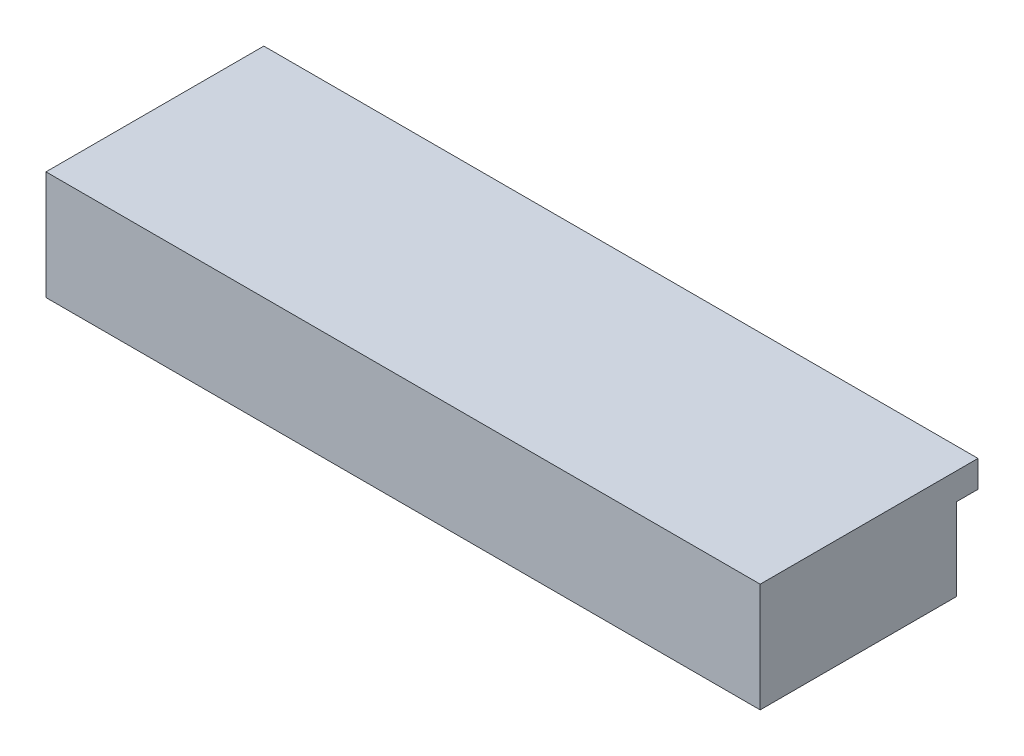
from build123d import *

# Parameters (mm, degrees)
ESQUISSE3_W      = 400
ESQUISSE3_H      = 40
EXTRUSION1_DEPTH = 110
ESQUISSE8_W      = 400
ESQUISSE8_H      = 122
EXTRUSION3_DEPTH = 15
ESQUISSE11_W     = 400
ESQUISSE11_H     = 110
EXTRUSION5_DEPTH = 6
ESQUISSE10_R     = 3
EXTRUSION4_DEPTH = 1
ESQUISSE12_R     = 3
EXTRUSION6_DEPTH = 20


with BuildPart() as part:
    # Esquisse3 → Extrusion1 (new body)
    with BuildSketch(Plane.XY):
        with Locations((38, 5)):
            Rectangle(ESQUISSE3_W, ESQUISSE3_H)
    extrude(amount=EXTRUSION1_DEPTH)

    # Esquisse8 → Extrusion3 (add)
    with BuildSketch(Plane(origin=(0, 25, 0), x_dir=(1, 0, 0), z_dir=(0, 1, 0))):
        with Locations((38, -49)):
            Rectangle(ESQUISSE8_W, ESQUISSE8_H)
    extrude(amount=EXTRUSION3_DEPTH)

    # Esquisse11 → Extrusion5 (add)
    with BuildSketch(Plane.XZ.offset(15)):
        with Locations((38, 55)):
            Rectangle(ESQUISSE11_W, ESQUISSE11_H)
    extrude(amount=EXTRUSION5_DEPTH)

    # Esquisse10 → Extrusion4 (cut)
    with BuildSketch(Plane(origin=(0, 0, 0), x_dir=(-1, 0, 0), z_dir=(0, 0, -1))):
        with BuildLine():
            Line((59.5, -8), (59.5, -19))
            ThreePointArc((59.5, -19), (58.914213562, -20.414213562), (57.5, -21))
            Line((57.5, -21), (-68.5, -21))
            ThreePointArc((-68.5, -21), (-69.914213562, -20.414213562), (-70.5, -19))
            Line((-70.5, -19), (-70.5, -8))
            ThreePointArc((-70.5, -8), (-71.085786438, -6.585786438), (-72.5, -6))
            Line((-72.5, -6), (-83, -6))
            ThreePointArc((-83, -6), (-95.5, 6.5), (-83, 19))
            Line((-83, 19), (70.25, 19))
            ThreePointArc((70.25, 19), (82.75, 6.5), (70.25, -6))
            Line((70.25, -6), (61.5, -6))
            ThreePointArc((61.5, -6), (60.085786438, -6.585786438), (59.5, -8))
        make_face()
        with Locations((-86.5, 6.5)):
            Circle(ESQUISSE10_R, mode=Mode.SUBTRACT)
        with Locations((-20.5, 6.5)):
            Circle(ESQUISSE10_R, mode=Mode.SUBTRACT)
        with Locations((72.75, 6.5)):
            Circle(ESQUISSE10_R, mode=Mode.SUBTRACT)
        with BuildLine():
            Line((-31.5, -3), (-61.5, -3))
            ThreePointArc((-61.5, -3), (-62.207106781, -2.707106781), (-62.5, -2))
            Line((-62.5, -2), (-62.5, 12))
            ThreePointArc((-62.5, 12), (-62.207106781, 12.707106781), (-61.5, 13))
            Line((-61.5, 13), (-31.5, 13))
            ThreePointArc((-31.5, 13), (-30.792893219, 12.707106781), (-30.5, 12))
            Line((-30.5, 12), (-30.5, -2))
            ThreePointArc((-30.5, -2), (-30.792893219, -2.707106781), (-31.5, -3))
        make_face(mode=Mode.SUBTRACT)
        with BuildLine():
            Line((51.75, 0), (12.75, 0))
            ThreePointArc((12.75, 0), (12.042893219, 0.292893219), (11.75, 1))
            Line((11.75, 1), (11.75, 11))
            ThreePointArc((11.75, 11), (12.042893219, 11.707106781), (12.75, 12))
            Line((12.75, 12), (51.75, 12))
            ThreePointArc((51.75, 12), (52.457106781, 11.707106781), (52.75, 11))
            Line((52.75, 11), (52.75, 1))
            ThreePointArc((52.75, 1), (52.457106781, 0.292893219), (51.75, 0))
        make_face(mode=Mode.SUBTRACT)
    extrude(amount=-EXTRUSION4_DEPTH, mode=Mode.SUBTRACT)

    # Esquisse12 → Extrusion6 (cut)
    with BuildSketch(Plane(origin=(0, 0, 0), x_dir=(-1, 0, 0), z_dir=(0, 0, -1))):
        with Locations((-86.5, 6.5)):
            Circle(ESQUISSE12_R)
        with Locations((-20.5, 6.5)):
            Circle(ESQUISSE12_R)
        with Locations((72.75, 6.5)):
            Circle(ESQUISSE12_R)
        with BuildLine():
            Line((-30.5, -2), (-30.5, 12))
            ThreePointArc((-30.5, 12), (-30.792893219, 12.707106781), (-31.5, 13))
            Line((-31.5, 13), (-61.5, 13))
            ThreePointArc((-61.5, 13), (-62.207106781, 12.707106781), (-62.5, 12))
            Line((-62.5, 12), (-62.5, -2))
            ThreePointArc((-62.5, -2), (-62.207106781, -2.707106781), (-61.5, -3))
            Line((-61.5, -3), (-31.5, -3))
            ThreePointArc((-31.5, -3), (-30.792893219, -2.707106781), (-30.5, -2))
        make_face()
        with BuildLine():
            Line((52.75, 1), (52.75, 11))
            ThreePointArc((52.75, 11), (52.457106781, 11.707106781), (51.75, 12))
            Line((51.75, 12), (12.75, 12))
            ThreePointArc((12.75, 12), (12.042893219, 11.707106781), (11.75, 11))
            Line((11.75, 11), (11.75, 1))
            ThreePointArc((11.75, 1), (12.042893219, 0.292893219), (12.75, 0))
            Line((12.75, 0), (51.75, 0))
            ThreePointArc((51.75, 0), (52.457106781, 0.292893219), (52.75, 1))
        make_face()
    extrude(amount=-EXTRUSION6_DEPTH, mode=Mode.SUBTRACT)


solid = part.part
